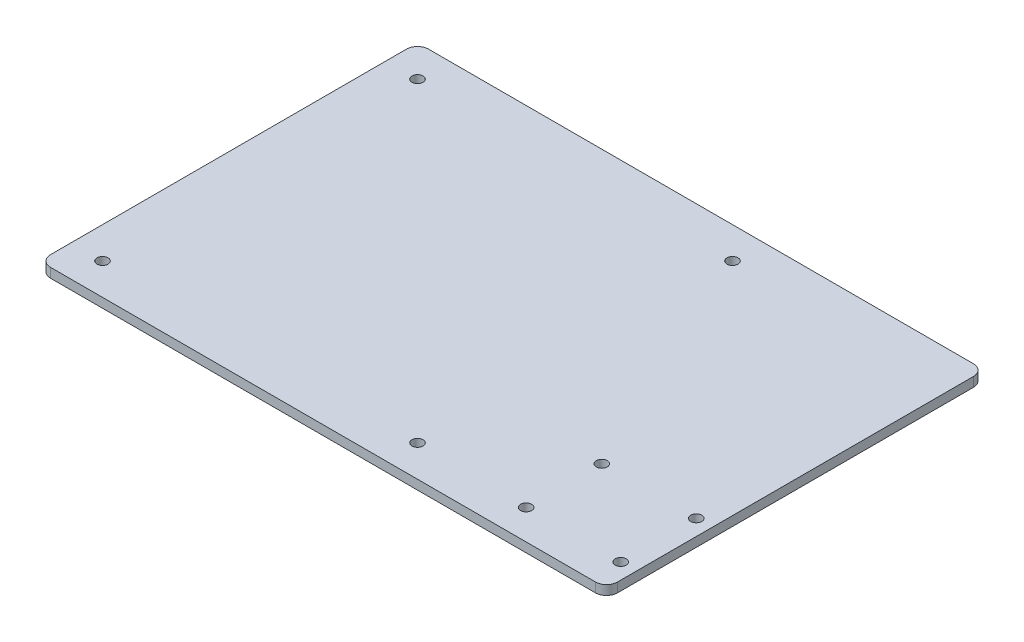
from build123d import *

# Parameters (mm, degrees)
SKETCH_2_W          = 180
SKETCH_2_H          = 120
EXTRUDE_1_DEPTH     = 3
FILLET_1_R          = 3.5
SKETCH_3_R          = 1.75
CUT_EXTRUDE_1_DEPTH = 4
SKETCH_4_R          = 1.75
CUT_EXTRUDE_2_DEPTH = 4


with BuildPart() as part:
    # 草图2 → 凸台-拉伸1 (new body)
    with BuildSketch(Plane(origin=(0, 0, 0), x_dir=(1, 0, 0), z_dir=(0, 1, 0))):
        with Locations((90, -60)):
            Rectangle(SKETCH_2_W, SKETCH_2_H)
    extrude(amount=EXTRUDE_1_DEPTH)

    # 圆角1
    fillet_1_edges = [part.edges().sort_by_distance(p)[0] for p in [
        (0, 1.5, 0),
        (180, 1.5, 0),
        (180, 1.5, 120),
        (0, 1.5, 120),
    ]]
    fillet(fillet_1_edges, radius=FILLET_1_R)

    # 草图3 → 切除-拉伸1 (cut, through all)
    with BuildSketch(Plane(origin=(0, 3, 0), x_dir=(1, 0, 0), z_dir=(0, 1, 0))):
        with Locations((175, -110.5)):
            Circle(SKETCH_3_R)
        with Locations((145, -110.5)):
            Circle(SKETCH_3_R)
        with Locations((175, -86.5)):
            Circle(SKETCH_3_R)
        with Locations((145, -86.5)):
            Circle(SKETCH_3_R)
    extrude(amount=-CUT_EXTRUDE_1_DEPTH, mode=Mode.SUBTRACT)

    # 草图4 → 切除-拉伸2 (cut, through all)
    with BuildSketch(Plane(origin=(0, 3, 0), x_dir=(1, 0, 0), z_dir=(0, 1, 0))):
        with Locations((110, -110)):
            Circle(SKETCH_4_R)
        with Locations((110, -10)):
            Circle(SKETCH_4_R)
        with Locations((10, -10)):
            Circle(SKETCH_4_R)
        with Locations((10, -110)):
            Circle(SKETCH_4_R)
    extrude(amount=-CUT_EXTRUDE_2_DEPTH, mode=Mode.SUBTRACT)


solid = part.part
